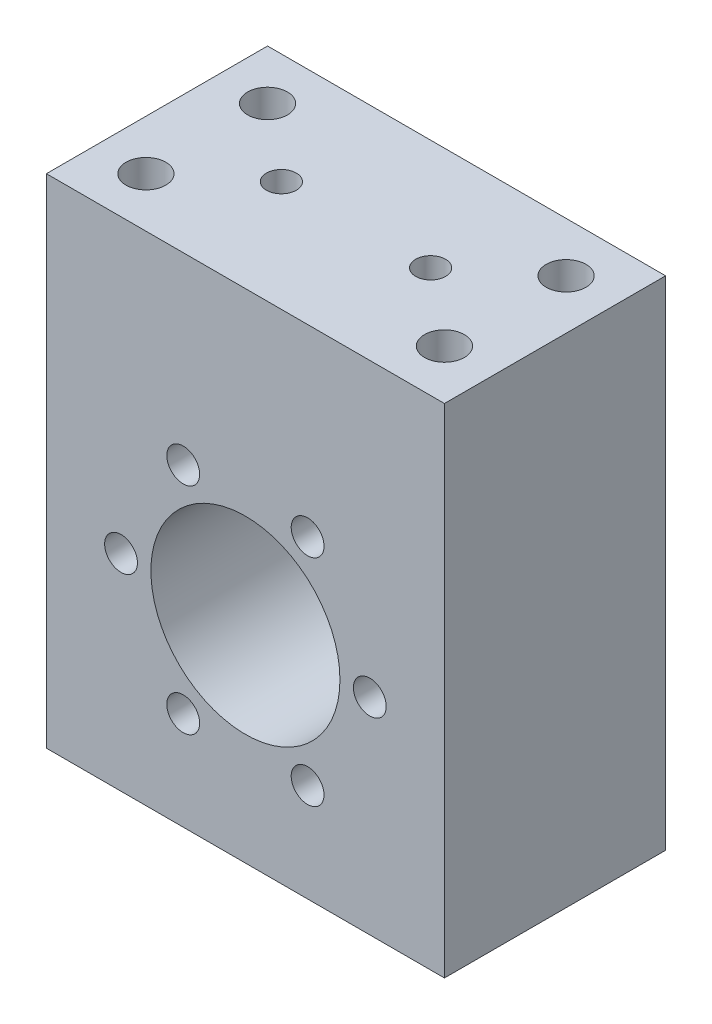
from build123d import *

# Parameters (mm, degrees)
ESBO_O2_W                = 80
ESBO_O2_H                = 117.2
RESSALTO_EXTRUS_O2_DEPTH = 22.225
ESBO_O3_R                = 19
CORTE_EXTRUS_O1_DEPTH    = 45.45
ESBO_O4_R                = 3.3
CORTE_EXTRUS_O2_DEPTH    = 34.5
PADR_OCIRCULAR1_COUNT    = 6
ESBO_O10_R               = 4
ESBO_O10_R_2             = 3
CORTE_EXTRUS_O5_DEPTH    = 30
ESBO_O12_W               = 80
ESBO_O12_H               = 17.2
CORTE_EXTRUS_O7_DEPTH    = 45.45


with BuildPart() as part:
    # Esboço2 → Ressalto-extrusão2 (new body, symmetric)
    with BuildSketch(Plane.XY):
        Rectangle(ESBO_O2_W, ESBO_O2_H)
    extrude(amount=RESSALTO_EXTRUS_O2_DEPTH, both=True)

    # Esboço3 → Corte-extrusão1 (cut, through all)
    with BuildSketch(Plane.XY.offset(22.225)):
        Circle(ESBO_O3_R)
    extrude(amount=-CORTE_EXTRUS_O1_DEPTH, mode=Mode.SUBTRACT)

    # Esboço4 → Corte-extrusão2 (cut)
    with BuildSketch(Plane.XY.offset(22.225)):
        with Locations((12.5, 21.650635095)):
            Circle(ESBO_O4_R)
    corte_extrus_o2 = extrude(amount=-CORTE_EXTRUS_O2_DEPTH, mode=Mode.SUBTRACT)

    # PadrãoCircular1: Corte-extrusão2 ×6 about axis
    padr_ocircular1_axis = Axis((0, 0, 0), (0, 0, 1))
    for i in range(1, PADR_OCIRCULAR1_COUNT):
        add(corte_extrus_o2.rotate(padr_ocircular1_axis, i * 360 / PADR_OCIRCULAR1_COUNT), mode=Mode.SUBTRACT)

    # Esboço10 → Corte-extrusão5 (cut)
    with BuildSketch(Plane(origin=(0, 58.6, 0), x_dir=(1, 0, 0), z_dir=(0, 1, 0))):
        with Locations((-30, 12.225)):
            Circle(ESBO_O10_R)
        with Locations((30, 12.225)):
            Circle(ESBO_O10_R)
        with Locations((-30, -12.225)):
            Circle(ESBO_O10_R)
        with Locations((30, -12.225)):
            Circle(ESBO_O10_R)
        with Locations((-15, 0)):
            Circle(ESBO_O10_R_2)
        with Locations((15, 0)):
            Circle(ESBO_O10_R_2)
    extrude(amount=-CORTE_EXTRUS_O5_DEPTH, mode=Mode.SUBTRACT)

    # Esboço12 → Corte-extrusão7 (cut, through all)
    with BuildSketch(Plane.XY.offset(22.225)):
        with Locations((0, -50)):
            Rectangle(ESBO_O12_W, ESBO_O12_H)
    extrude(amount=-CORTE_EXTRUS_O7_DEPTH, mode=Mode.SUBTRACT)


solid = part.part
